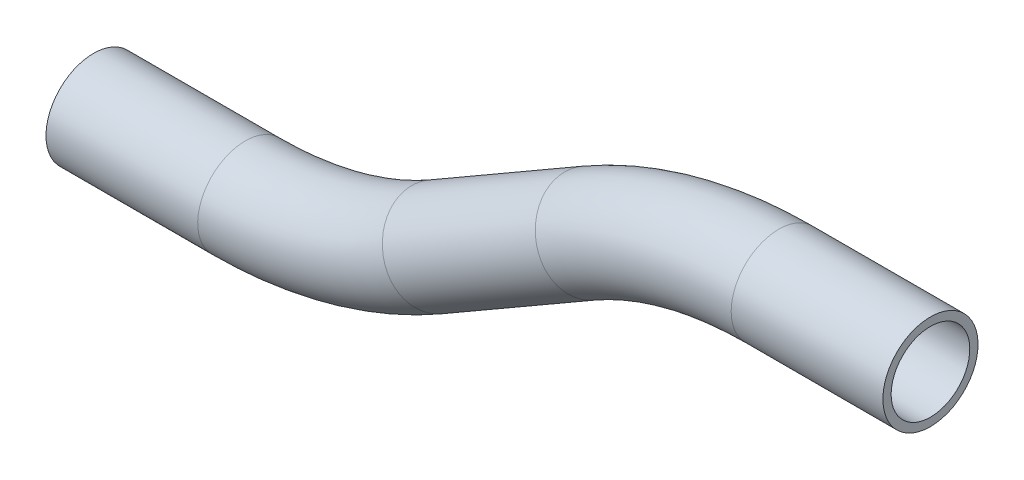
from build123d import *

# Parameters (mm, degrees)
SKETCH2_R   = 9.525
SKETCH2_R_2 = 7.874


with BuildPart() as part:
    # Sweep1: sweep along a path in Sketch1
    with BuildLine(Plane.XY) as sweep1_path:
        Line((30.382271537, 0), (0, 0))
        ThreePointArc((0, 0), (-19.722011237, -2.596452037), (-38.1, -10.208864232))
        Line((-38.1, -10.208864232), (-68.726592695, -27.891135768))
        ThreePointArc((-68.726592695, -27.891135768), (-87.104581458, -35.503547963), (-106.826592695, -38.1))
        Line((-106.826592695, -38.1), (-137.208864232, -38.1))
    # Sketch2 → Sweep1 (sweep)
    with BuildSketch(Plane.ZY.offset(-30.382271537)):
        Circle(SKETCH2_R)
        Circle(SKETCH2_R_2, mode=Mode.SUBTRACT)
    sweep(path=sweep1_path.line)


solid = part.part
